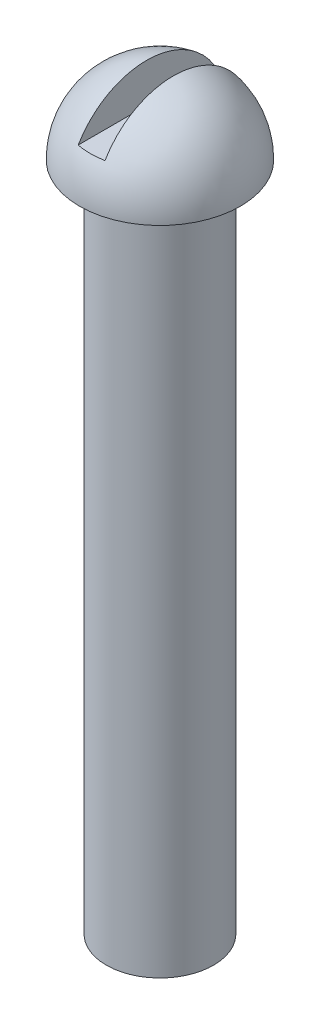
from build123d import *

# Parameters (mm, degrees)
SKETCH1_W               = 2
SKETCH1_H               = 25
SKETCH2_W               = 0.5
SKETCH2_H               = 1.642734333
CUT_EXTRUDE1_DEPTH      = 4
CUT_EXTRUDE1_DEPTH_BACK = 4


with BuildPart() as part:
    # Sketch1 → Revolve1 (revolve)
    with BuildSketch(Plane.XY):
        with Locations((1, -12.5)):
            Rectangle(SKETCH1_W, SKETCH1_H)
        with BuildLine():
            Line((0, 0), (3, 0))
            ThreePointArc((3, 0), (2.121320344, 2.121320344), (0, 3))
            Line((0, 3), (0, 0))
        make_face()
    revolve(axis=Axis((0, 3, 0), (0, -1, 0)))

    # Sketch2 → Cut-Extrude1 (cut, two sides)
    with BuildSketch(Plane.XY) as cut_extrude1_sk:
        with Locations((-0.25, 2.321367166)):
            Rectangle(SKETCH2_W, SKETCH2_H)
        with Locations((0.25, 2.321367166)):
            Rectangle(SKETCH2_W, SKETCH2_H)
    extrude(amount=CUT_EXTRUDE1_DEPTH, mode=Mode.SUBTRACT)
    extrude(cut_extrude1_sk.sketch, amount=-CUT_EXTRUDE1_DEPTH_BACK, mode=Mode.SUBTRACT)


solid = part.part
